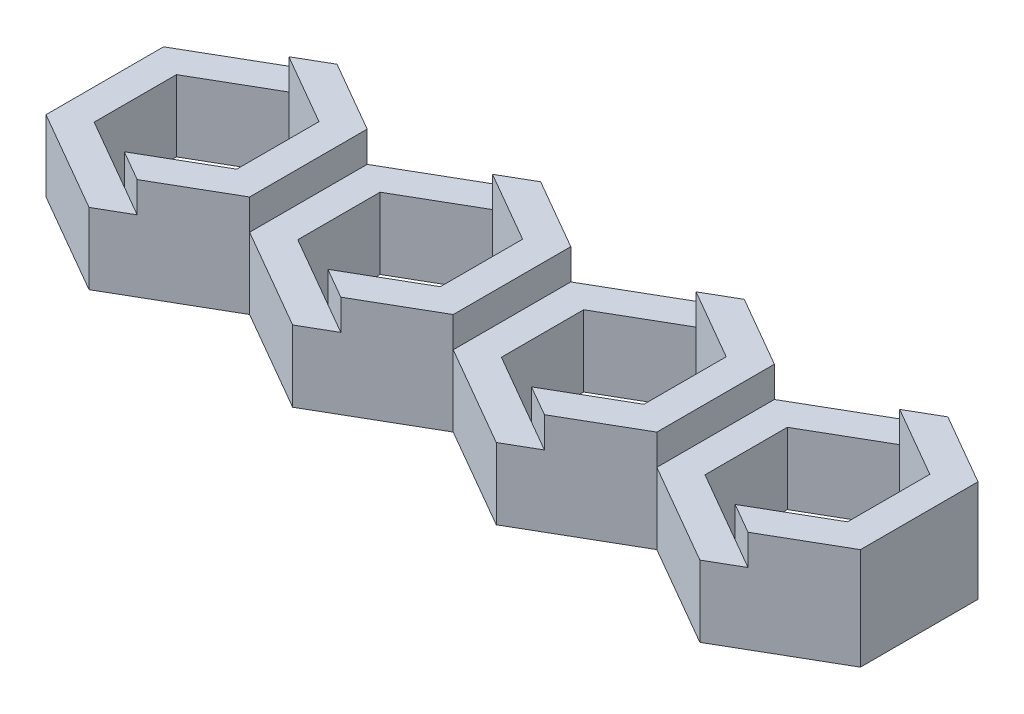
from build123d import *

# Parameters (mm, degrees)
BOSS_EXTRUDE3_DEPTH   = 10
BOSS_EXTRUDE3_2_DEPTH = 10
BOSS_EXTRUDE3_3_DEPTH = 10
BOSS_EXTRUDE3_4_DEPTH = 10
BOSS_EXTRUDE4_DEPTH   = 7


with BuildPart() as part:
    # Sketch1 → Boss-Extrude3 (new body)
    with BuildSketch(Plane(origin=(0, 0, 0), x_dir=(1, 0, 0), z_dir=(0, 1, 0))):
        Polygon((54.860811185, -22.01303097), (54.860811185, -10.466025586), (47.860811185, -6.424573702), (44.860811185, -8.156624509), (51.860811185, -12.198076394), (51.860811185, -20.280980162), (44.860811185, -24.322432047), (47.860811185, -26.054482854), align=None)
    extrude(amount=BOSS_EXTRUDE3_DEPTH)



with BuildPart() as body_2:
    # Sketch1 → Boss-Extrude3 2 (new body)
    with BuildSketch(Plane(origin=(0, 0, 0), x_dir=(1, 0, 0), z_dir=(0, 1, 0))):
        Polygon((-12.139188815, -6.424573702), (-15.139188815, -8.156624509), (-8.139188815, -12.198076394), (-8.139188815, -20.280980162), (-15.139188815, -24.322432047), (-12.139188815, -26.054482854), (-5.139188815, -22.01303097), (-5.139188815, -10.466025586), align=None)
    extrude(amount=BOSS_EXTRUDE3_2_DEPTH)


with BuildPart() as body_3:
    # Sketch1 → Boss-Extrude3 3 (new body)
    with BuildSketch(Plane(origin=(0, 0, 0), x_dir=(1, 0, 0), z_dir=(0, 1, 0))):
        Polygon((34.860811185, -10.466025586), (27.860811185, -6.424573702), (24.860811185, -8.156624509), (31.860811185, -12.198076394), (31.860811185, -20.280980162), (24.860811185, -24.322432047), (27.860811185, -26.054482854), (34.860811185, -22.01303097), align=None)
    extrude(amount=BOSS_EXTRUDE3_3_DEPTH)


with BuildPart() as body_4:
    # Sketch1 → Boss-Extrude3 4 (new body)
    with BuildSketch(Plane(origin=(0, 0, 0), x_dir=(1, 0, 0), z_dir=(0, 1, 0))):
        Polygon((7.860811185, -6.424573702), (4.860811185, -8.156624509), (11.860811185, -12.198076394), (11.860811185, -20.280980162), (4.860811185, -24.322432047), (7.860811185, -26.054482854), (14.860811185, -22.01303097), (14.860811185, -10.466025586), align=None)
    extrude(amount=BOSS_EXTRUDE3_4_DEPTH)


with BuildPart() as part_1:
    add(part.part)

    add(body_2.part)  # Boss-Extrude4 merges body 2

    add(body_3.part)  # Boss-Extrude4 merges body 3

    add(body_4.part)  # Boss-Extrude4 merges body 4
    # Sketch1_8 → Boss-Extrude4 (add)
    with BuildSketch(Plane(origin=(0, 0, 0), x_dir=(1, 0, 0), z_dir=(0, 1, 0))):
        Polygon((-22.139188815, -12.198076394), (-12.139188815, -6.424573702), (-15.139188815, -4.692522894), (-25.139188815, -10.466025586), (-25.139188815, -22.01303097), (-15.139188815, -27.786533662), (-12.139188815, -26.054482854), (-22.139188815, -20.280980162), align=None)
        Polygon((44.860811185, -8.156624509), (47.860811185, -6.424573702), (44.860811185, -4.692522894), (34.860811185, -10.466025586), (34.860811185, -22.01303097), (44.860811185, -27.786533662), (47.860811185, -26.054482854), (37.860811185, -20.280980162), (37.860811185, -12.198076394), align=None)
        Polygon((-2.139188815, -12.198076394), (7.860811185, -6.424573702), (4.860811185, -4.692522894), (-5.139188815, -10.466025586), (-5.139188815, -22.01303097), (4.860811185, -27.786533662), (7.860811185, -26.054482854), (-2.139188815, -20.280980162), align=None)
        Polygon((27.860811185, -6.424573702), (24.860811185, -4.692522894), (14.860811185, -10.466025586), (14.860811185, -22.01303097), (24.860811185, -27.786533662), (27.860811185, -26.054482854), (17.860811185, -20.280980162), (17.860811185, -12.198076394), align=None)
    extrude(amount=BOSS_EXTRUDE4_DEPTH)


solid = part_1.part
